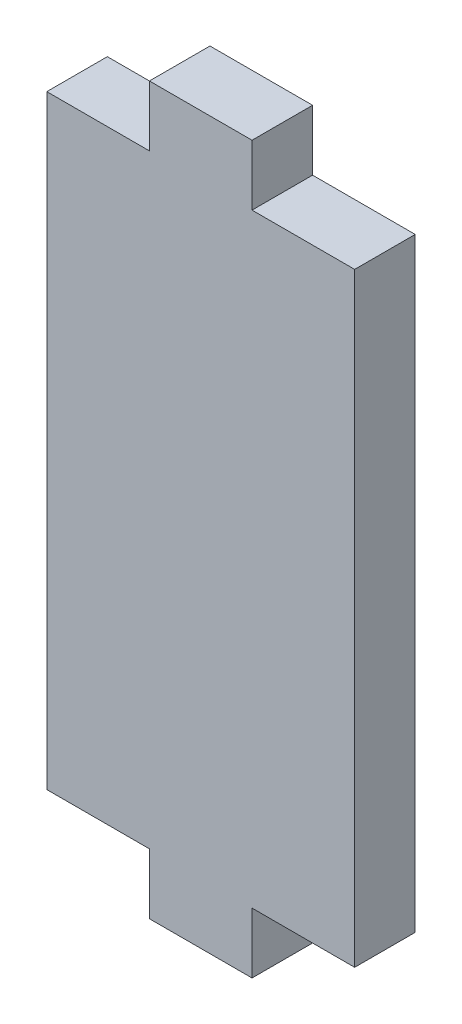
from build123d import *

# Parameters (mm, degrees)
SKETCH1_W           = 10
SKETCH1_H           = 5.9
BOSS_EXTRUDE1_DEPTH = 5.9


with BuildPart() as part:
    # Sketch1 → Boss-Extrude1 (new body)
    with BuildSketch(Plane.XY):
        with Locations((0, 32.4)):
            Rectangle(SKETCH1_W, SKETCH1_H)
        with Locations((0, 26.5)):
            Rectangle(SKETCH1_W, SKETCH1_H)
        Polygon((-15, 29.45), (-15, -29.45), (-5, -29.45), (-5, -23.55), (5, -23.55), (5, -29.45), (15, -29.45), (15, 29.45), (5, 29.45), (5, 23.55), (-5, 23.55), (-5, 29.45), align=None)
        with Locations((0, -26.5)):
            Rectangle(SKETCH1_W, SKETCH1_H)
        with Locations((0, -32.4)):
            Rectangle(SKETCH1_W, SKETCH1_H)
    extrude(amount=BOSS_EXTRUDE1_DEPTH)


solid = part.part
